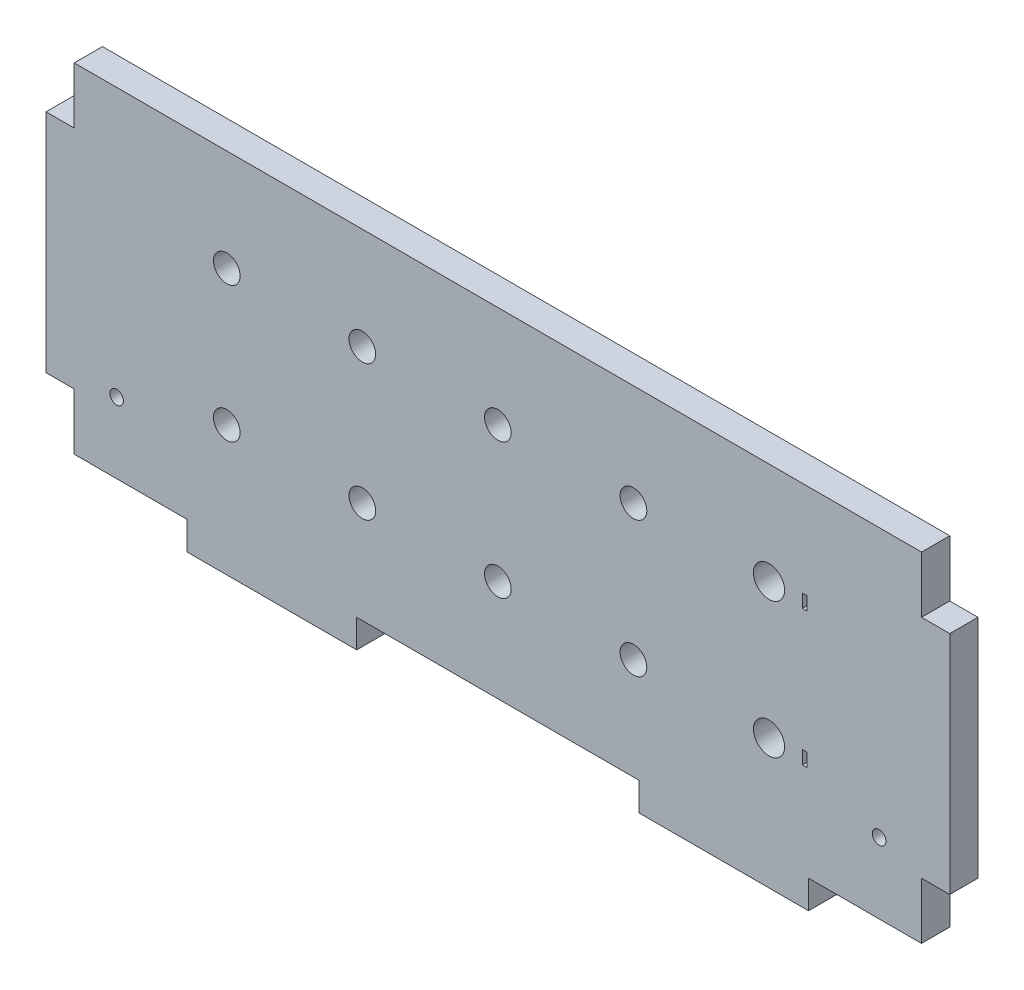
from build123d import *

# Parameters (mm, degrees)
SKETCH1_W           = 190.5
SKETCH1_H           = 76.2
BOSS_EXTRUDE1_DEPTH = 6.35
SKETCH2_W           = 6.35
SKETCH2_H           = 50.8
BOSS_EXTRUDE2_DEPTH = 6.35
SKETCH3_W           = 6.35
SKETCH3_H           = 50.8
BOSS_EXTRUDE3_DEPTH = 6.35
SKETCH4_W           = 38.1
SKETCH4_H           = 6.35
BOSS_EXTRUDE4_DEPTH = 6.35
CUT_EXTRUDE1_REACH  = 8.35
SKETCH7_R           = 3
SKETCH7_R_2         = 3.5
SKETCH7_W           = 1
SKETCH7_H           = 3
SKETCH8_R           = 1.524
CUT_EXTRUDE2_DEPTH  = 6.35


with BuildPart() as part:
    # Sketch1 → Boss-Extrude1 (new body)
    with BuildSketch(Plane.XY):
        Rectangle(SKETCH1_W, SKETCH1_H)
    extrude(amount=BOSS_EXTRUDE1_DEPTH)

    # Sketch2 → Boss-Extrude2 (add)
    with BuildSketch(Plane.ZY.offset(95.25)):
        with Locations((3.175, 0)):
            Rectangle(SKETCH2_W, SKETCH2_H)
    extrude(amount=BOSS_EXTRUDE2_DEPTH)

    # Sketch3 → Boss-Extrude3 (add)
    with BuildSketch(Plane(origin=(95.25, 0, 0), x_dir=(0, 0, -1), z_dir=(1, 0, 0))):
        with Locations((-3.175, 0)):
            Rectangle(SKETCH3_W, SKETCH3_H)
    extrude(amount=BOSS_EXTRUDE3_DEPTH)

    # Sketch4 → Boss-Extrude4 (add)
    with BuildSketch(Plane.XZ.offset(38.1)):
        with Locations((-50.8, 3.175)):
            Rectangle(SKETCH4_W, SKETCH4_H)
        with Locations((50.8, 3.175)):
            Rectangle(SKETCH4_W, SKETCH4_H)
    extrude(amount=BOSS_EXTRUDE4_DEPTH)

    # Sketch7 → Cut-Extrude1 (cut, up to next)
    with BuildSketch(Plane(origin=(0, 0, 0), x_dir=(-1, 0, 0), z_dir=(0, 0, -1)), mode=Mode.PRIVATE) as cut_extrude1_sk1:
        with Locations((-30.48, 15.24)):
            Circle(SKETCH7_R)
    cut_extrude1_tool1 = extrude(cut_extrude1_sk1.sketch, amount=-CUT_EXTRUDE1_REACH, mode=Mode.PRIVATE) & part.part
    add(cut_extrude1_tool1.solids().sort_by_distance((30.48, 15.24, 0))[0], mode=Mode.SUBTRACT)
    # Sketch7 → Cut-Extrude1 (cut, up to next)
    with BuildSketch(Plane(origin=(0, 0, 0), x_dir=(-1, 0, 0), z_dir=(0, 0, -1)), mode=Mode.PRIVATE) as cut_extrude1_sk2:
        with Locations((0, 15.24)):
            Circle(SKETCH7_R)
    cut_extrude1_tool2 = extrude(cut_extrude1_sk2.sketch, amount=-CUT_EXTRUDE1_REACH, mode=Mode.PRIVATE) & part.part
    add(cut_extrude1_tool2.solids().sort_by_distance((0, 15.24, 0))[0], mode=Mode.SUBTRACT)
    # Sketch7 → Cut-Extrude1 (cut, up to next)
    with BuildSketch(Plane(origin=(0, 0, 0), x_dir=(-1, 0, 0), z_dir=(0, 0, -1)), mode=Mode.PRIVATE) as cut_extrude1_sk3:
        with Locations((30.48, 15.24)):
            Circle(SKETCH7_R)
    cut_extrude1_tool3 = extrude(cut_extrude1_sk3.sketch, amount=-CUT_EXTRUDE1_REACH, mode=Mode.PRIVATE) & part.part
    add(cut_extrude1_tool3.solids().sort_by_distance((-30.48, 15.24, 0))[0], mode=Mode.SUBTRACT)
    # Sketch7 → Cut-Extrude1 (cut, up to next)
    with BuildSketch(Plane(origin=(0, 0, 0), x_dir=(-1, 0, 0), z_dir=(0, 0, -1)), mode=Mode.PRIVATE) as cut_extrude1_sk4:
        with Locations((60.96, 15.24)):
            Circle(SKETCH7_R)
    cut_extrude1_tool4 = extrude(cut_extrude1_sk4.sketch, amount=-CUT_EXTRUDE1_REACH, mode=Mode.PRIVATE) & part.part
    add(cut_extrude1_tool4.solids().sort_by_distance((-60.96, 15.24, 0))[0], mode=Mode.SUBTRACT)
    # Sketch7 → Cut-Extrude1 (cut, up to next)
    with BuildSketch(Plane(origin=(0, 0, 0), x_dir=(-1, 0, 0), z_dir=(0, 0, -1)), mode=Mode.PRIVATE) as cut_extrude1_sk5:
        with Locations((0, -15.24)):
            Circle(SKETCH7_R)
    cut_extrude1_tool5 = extrude(cut_extrude1_sk5.sketch, amount=-CUT_EXTRUDE1_REACH, mode=Mode.PRIVATE) & part.part
    add(cut_extrude1_tool5.solids().sort_by_distance((0, -15.24, 0))[0], mode=Mode.SUBTRACT)
    # Sketch7 → Cut-Extrude1 (cut, up to next)
    with BuildSketch(Plane(origin=(0, 0, 0), x_dir=(-1, 0, 0), z_dir=(0, 0, -1)), mode=Mode.PRIVATE) as cut_extrude1_sk6:
        with Locations((30.48, -15.24)):
            Circle(SKETCH7_R)
    cut_extrude1_tool6 = extrude(cut_extrude1_sk6.sketch, amount=-CUT_EXTRUDE1_REACH, mode=Mode.PRIVATE) & part.part
    add(cut_extrude1_tool6.solids().sort_by_distance((-30.48, -15.24, 0))[0], mode=Mode.SUBTRACT)
    # Sketch7 → Cut-Extrude1 (cut, up to next)
    with BuildSketch(Plane(origin=(0, 0, 0), x_dir=(-1, 0, 0), z_dir=(0, 0, -1)), mode=Mode.PRIVATE) as cut_extrude1_sk7:
        with Locations((60.96, -15.24)):
            Circle(SKETCH7_R)
    cut_extrude1_tool7 = extrude(cut_extrude1_sk7.sketch, amount=-CUT_EXTRUDE1_REACH, mode=Mode.PRIVATE) & part.part
    add(cut_extrude1_tool7.solids().sort_by_distance((-60.96, -15.24, 0))[0], mode=Mode.SUBTRACT)
    # Sketch7 → Cut-Extrude1 (cut, up to next)
    with BuildSketch(Plane(origin=(0, 0, 0), x_dir=(-1, 0, 0), z_dir=(0, 0, -1)), mode=Mode.PRIVATE) as cut_extrude1_sk8:
        with Locations((-30.48, -15.24)):
            Circle(SKETCH7_R)
    cut_extrude1_tool8 = extrude(cut_extrude1_sk8.sketch, amount=-CUT_EXTRUDE1_REACH, mode=Mode.PRIVATE) & part.part
    add(cut_extrude1_tool8.solids().sort_by_distance((30.48, -15.24, 0))[0], mode=Mode.SUBTRACT)
    # Sketch7 → Cut-Extrude1 (cut, up to next)
    with BuildSketch(Plane(origin=(0, 0, 0), x_dir=(-1, 0, 0), z_dir=(0, 0, -1)), mode=Mode.PRIVATE) as cut_extrude1_sk9:
        with Locations((-60.96, 15.24)):
            Circle(SKETCH7_R_2)
    cut_extrude1_tool9 = extrude(cut_extrude1_sk9.sketch, amount=-CUT_EXTRUDE1_REACH, mode=Mode.PRIVATE) & part.part
    add(cut_extrude1_tool9.solids().sort_by_distance((60.96, 15.24, 0))[0], mode=Mode.SUBTRACT)
    # Sketch7 → Cut-Extrude1 (cut, up to next)
    with BuildSketch(Plane(origin=(0, 0, 0), x_dir=(-1, 0, 0), z_dir=(0, 0, -1)), mode=Mode.PRIVATE) as cut_extrude1_sk10:
        with Locations((-60.96, -15.24)):
            Circle(SKETCH7_R_2)
    cut_extrude1_tool10 = extrude(cut_extrude1_sk10.sketch, amount=-CUT_EXTRUDE1_REACH, mode=Mode.PRIVATE) & part.part
    add(cut_extrude1_tool10.solids().sort_by_distance((60.96, -15.24, 0))[0], mode=Mode.SUBTRACT)
    # Sketch7 → Cut-Extrude1 (cut, up to next)
    with BuildSketch(Plane(origin=(0, 0, 0), x_dir=(-1, 0, 0), z_dir=(0, 0, -1)), mode=Mode.PRIVATE) as cut_extrude1_sk11:
        with Locations((-68.96, 15.24)):
            Rectangle(SKETCH7_W, SKETCH7_H)
    cut_extrude1_tool11 = extrude(cut_extrude1_sk11.sketch, amount=-CUT_EXTRUDE1_REACH, mode=Mode.PRIVATE) & part.part
    add(cut_extrude1_tool11.solids().sort_by_distance((68.96, 15.24, 0))[0], mode=Mode.SUBTRACT)
    # Sketch7 → Cut-Extrude1 (cut, up to next)
    with BuildSketch(Plane(origin=(0, 0, 0), x_dir=(-1, 0, 0), z_dir=(0, 0, -1)), mode=Mode.PRIVATE) as cut_extrude1_sk12:
        with Locations((-68.96, -15.24)):
            Rectangle(SKETCH7_W, SKETCH7_H)
    cut_extrude1_tool12 = extrude(cut_extrude1_sk12.sketch, amount=-CUT_EXTRUDE1_REACH, mode=Mode.PRIVATE) & part.part
    add(cut_extrude1_tool12.solids().sort_by_distance((68.96, -15.24, 0))[0], mode=Mode.SUBTRACT)

    # Sketch8 → Cut-Extrude2 (cut)
    with BuildSketch(Plane(origin=(23.763692911, 98.5857123, 6.35), x_dir=(1, 0, 0), z_dir=(0, 0, 1))):
        with Locations((-109.488692911, -120.8107123)):
            Circle(SKETCH8_R)
        with Locations((61.961307089, -120.8107123)):
            Circle(SKETCH8_R)
    extrude(amount=-CUT_EXTRUDE2_DEPTH, mode=Mode.SUBTRACT)


solid = part.part
